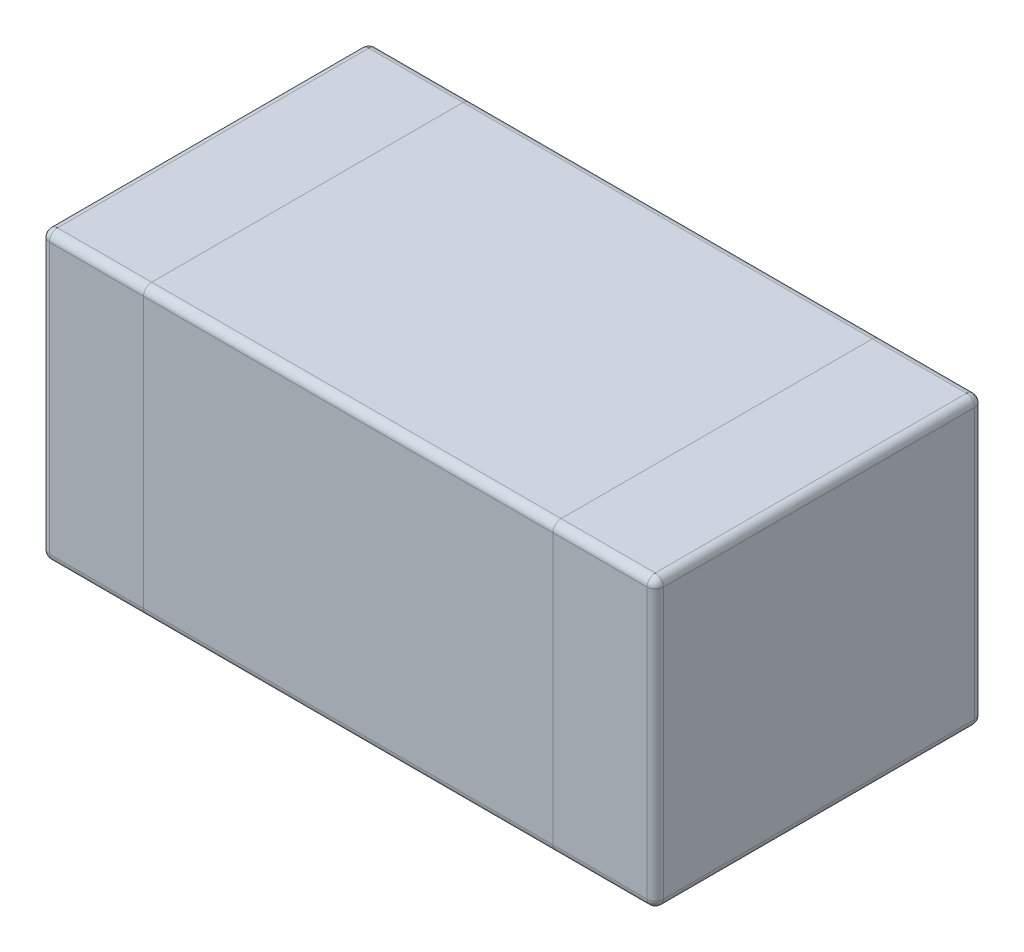
from build123d import *

# Parameters (mm, degrees)
BOSS_EXTRUDE1_DEPTH = 0.35
FILLET2_R           = 0.02


with BuildPart() as part:
    # Sketch1 → Boss-Extrude1 (new body, symmetric)
    with BuildSketch(Plane(origin=(0, 0, 0), x_dir=(1, 0, 0), z_dir=(0, 1, 0))):
        with BuildLine():
            Line((-0.73, -0.4), (0.73, -0.4))
            ThreePointArc((0.73, -0.4), (0.744142136, -0.394142136), (0.75, -0.38))
            Line((0.75, -0.38), (0.75, 0.38))
            ThreePointArc((0.75, 0.38), (0.744142136, 0.394142136), (0.73, 0.4))
            Line((0.73, 0.4), (-0.73, 0.4))
            ThreePointArc((-0.73, 0.4), (-0.744142136, 0.394142136), (-0.75, 0.38))
            Line((-0.75, 0.38), (-0.75, -0.38))
            ThreePointArc((-0.75, -0.38), (-0.744142136, -0.394142136), (-0.73, -0.4))
        make_face()
    extrude(amount=BOSS_EXTRUDE1_DEPTH, both=True)

    # Fillet2
    fillet2_edges = [part.edges().sort_by_distance(p)[0] for p in [
        (0.744142136, 0.35, 0.394142136),
        (0, -0.35, 0.4),
        (-0.744142136, -0.35, 0.394142136),
        (0.75, 0.35, 0),
        (0.744142136, 0.35, -0.394142136),
        (0, 0.35, -0.4),
        (-0.744142136, 0.35, -0.394142136),
        (-0.75, 0.35, 0),
        (0, 0.35, 0.4),
        (0, 0.35, -0.4),
        (0, 0.35, -0.4),
        (0, 0.35, 0.4),
        (0, -0.35, 0.4),
        (0, -0.35, 0.4),
        (0, -0.35, -0.4),
        (0, -0.35, -0.4),
        (-0.744142136, 0.35, 0.394142136),
        (0, 0.35, 0.4),
        (-0.75, -0.35, 0),
        (-0.744142136, -0.35, -0.394142136),
        (0, -0.35, -0.4),
        (0.744142136, -0.35, -0.394142136),
        (0.75, -0.35, 0),
        (0.744142136, -0.35, 0.394142136),
    ]]
    fillet(fillet2_edges, radius=FILLET2_R)


solid = part.part
